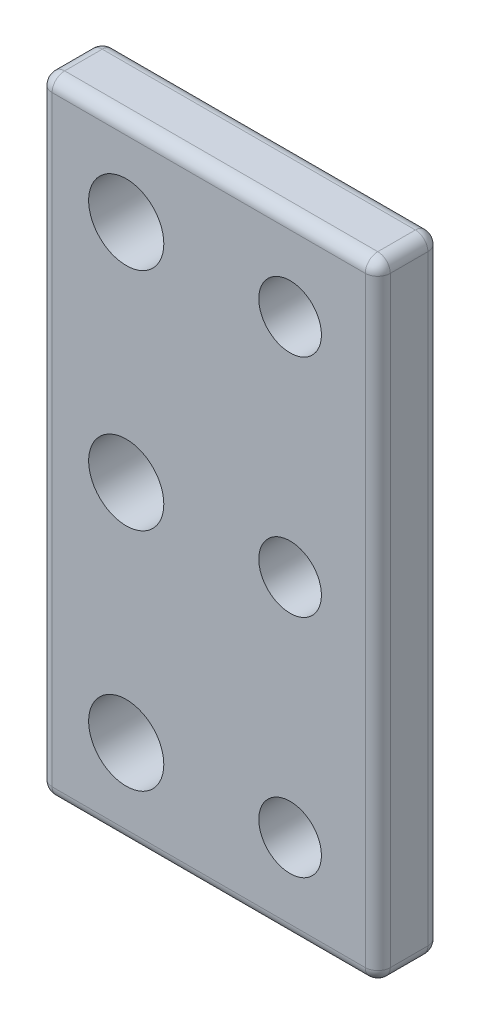
from build123d import *

# Parameters (mm, degrees)
SKETCH1_W           = 27
SKETCH1_H           = 50
SKETCH1_R           = 3
SKETCH1_R_2         = 2.5
BOSS_EXTRUDE1_DEPTH = 5
FILLET2_R           = 1


with BuildPart() as part:
    # Sketch1 → Boss-Extrude1 (new body)
    with BuildSketch(Plane.XY):
        Rectangle(SKETCH1_W, SKETCH1_H)
        with Locations((-6.582992823, 18)):
            Circle(SKETCH1_R, mode=Mode.SUBTRACT)
        with Locations((-6.582992823, 0)):
            Circle(SKETCH1_R, mode=Mode.SUBTRACT)
        with Locations((-6.582992823, -18)):
            Circle(SKETCH1_R, mode=Mode.SUBTRACT)
        with Locations((6.5, 18)):
            Circle(SKETCH1_R_2, mode=Mode.SUBTRACT)
        with Locations((6.5, 0)):
            Circle(SKETCH1_R_2, mode=Mode.SUBTRACT)
        with Locations((6.5, -18)):
            Circle(SKETCH1_R_2, mode=Mode.SUBTRACT)
    extrude(amount=BOSS_EXTRUDE1_DEPTH)

    # Fillet2
    fillet2_edges = [part.edges().sort_by_distance(p)[0] for p in [
        (-13.5, 0, 5),
        (0, -25, 5),
        (13.5, 0, 5),
        (0, -25, 0),
        (-13.5, 0, 0),
        (0, 25, 0),
        (13.5, 0, 0),
        (13.5, -25, 2.5),
        (-13.5, -25, 2.5),
        (-13.5, 25, 2.5),
        (13.5, 25, 2.5),
        (0, 25, 5),
    ]]
    fillet(fillet2_edges, radius=FILLET2_R)


solid = part.part
